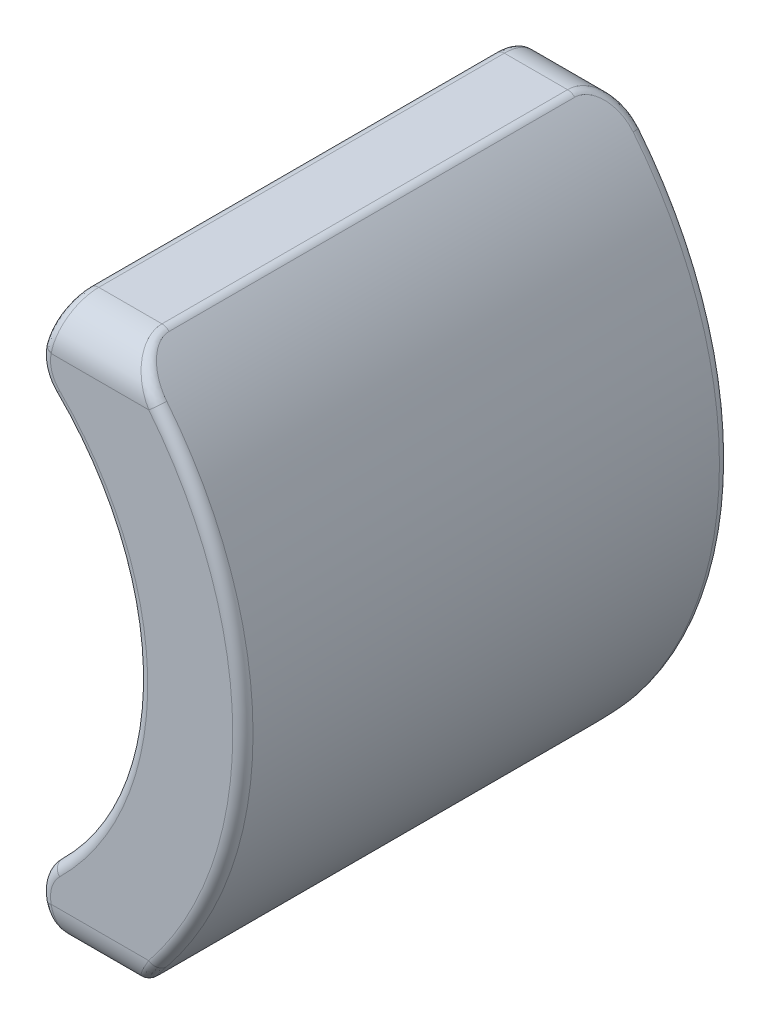
from build123d import *

# Parameters (mm, degrees)
BOSS_EXTRUDE1_DEPTH = 12
FILLET1_R           = 1
FILLET2_R           = 1
FILLET3_R           = 0.25


with BuildPart() as part:
    # Sketch1 → Boss-Extrude1 (new body)
    with BuildSketch(Plane.XY):
        with BuildLine():
            Line((6.738137725, -6.88), (4.878137725, -6.88))
            Line((4.878137725, -6.88), (4.531835438, -5.38))
            ThreePointArc((4.531835438, -5.38), (7.034339517, 0), (4.531835438, 5.38))
            Line((4.531835438, 5.38), (4.878137725, 6.88))
            Line((4.878137725, 6.88), (6.738137725, 6.88))
            ThreePointArc((6.738137725, 6.88), (9.63, 0), (6.738137725, -6.88))
        make_face()
    extrude(amount=BOSS_EXTRUDE1_DEPTH)

    # Fillet1
    fillet1_edges = [part.edges().sort_by_distance(p)[0] for p in [
        (4.531835438, -5.38, 6),
        (4.531835438, 5.38, 6),
    ]]
    fillet(fillet1_edges, radius=FILLET1_R)

    # Fillet2
    fillet2_edges = [part.edges().sort_by_distance(p)[0] for p in [
        (5.808137725, -6.88, 0),
        (5.808137725, -6.88, 12),
        (5.808137725, 6.88, 12),
        (5.808137725, 6.88, 0),
    ]]
    fillet(fillet2_edges, radius=FILLET2_R)

    # Fillet3
    fillet3_edges = [part.edges().sort_by_distance(p)[0] for p in [
        (7.034339517, 0, 0),
        (7.034339517, 0, 12),
        (4.687877266, 5.411310183, 0),
        (4.687877266, -5.411310183, 12),
        (6.738137725, -6.88, 6),
        (4.878137725, -6.88, 6),
        (9.63, 0, 0),
        (6.738137725, 6.88, 6),
        (9.63, 0, 12),
        (7.064336577, 6.544619807, 0.2528183),
        (7.064336577, 6.544619807, 11.7471817),
        (7.064336589, -6.544619821, 11.747181705),
        (7.064336577, -6.544619807, 0.2528183),
        (4.687877266, -5.411310183, 0),
        (4.655934772, -5.914769545, 11.999395357),
        (4.655934772, -5.914769545, 0.000604643),
        (4.815123489, -6.607055355, 11.686578845),
        (4.815123489, -6.607055355, 0.313421155),
        (4.687877266, 5.411310183, 12),
        (4.655934776, 5.914769544, 0.00060465),
        (4.655934776, 5.914769544, 11.99939535),
        (4.878137725, 6.88, 6),
        (4.815123489, 6.607055355, 0.313421155),
        (4.815123489, 6.607055355, 11.686578845),
    ]]
    fillet(fillet3_edges, radius=FILLET3_R)


solid = part.part
